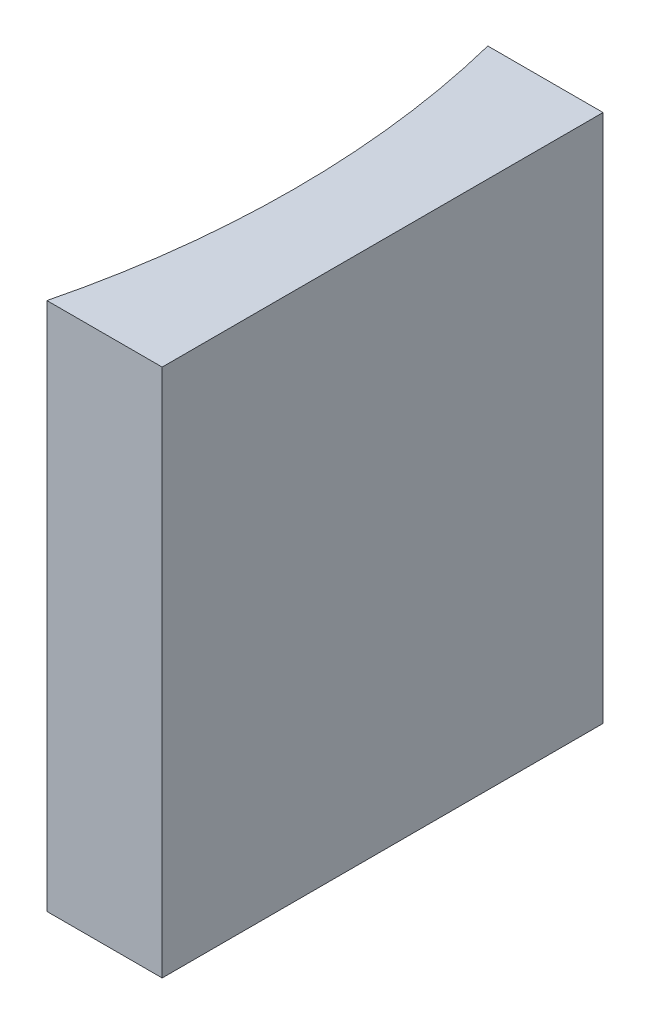
from build123d import *

# Parameters (mm, degrees)
EXTRUDE_1_DEPTH = 12


with BuildPart() as part:
    # 草图1 → 凸台-拉伸1 (new body)
    with BuildSketch(Plane(origin=(0, 0, 0), x_dir=(1, 0, 0), z_dir=(0, 1, 0))):
        with BuildLine():
            Line((0, 0), (0, -10))
            Line((0, -10), (-2.613550389, -10))
            ThreePointArc((-2.613550389, -10), (-2, -5), (-2.613550389, 0))
            Line((-2.613550389, 0), (0, 0))
        make_face()
    extrude(amount=EXTRUDE_1_DEPTH)


solid = part.part
